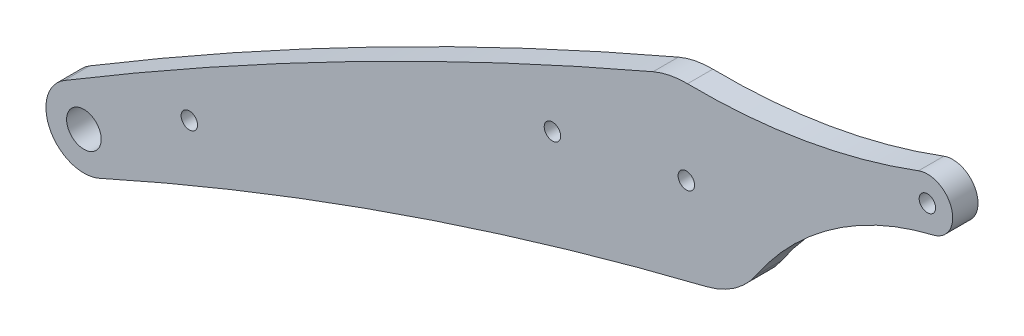
from build123d import *

# Parameters (mm, degrees)
SKETCH1_R           = 1.95
SKETCH1_R_2         = 4.1
BOSS_EXTRUDE1_DEPTH = 6


with BuildPart() as part:
    # Sketch1 → Boss-Extrude1 (new body)
    with BuildSketch(Plane.XY):
        with BuildLine():
            ThreePointArc((-249.547735749, 127.673100022), (-252.877471407, 115.79000474), (-241.215192405, 111.754370772))
            ThreePointArc((-241.215192405, 111.754370772), (-170.350070338, 139.847528819), (-97.252990361, 161.478708942))
            ThreePointArc((-97.252990361, 161.478708942), (-90.570551573, 164.523097822), (-85.437324527, 169.774123618))
            ThreePointArc((-85.437324527, 169.774123618), (-67.229564843, 188.321481613), (-43.509998386, 198.94735421))
            ThreePointArc((-43.509998386, 198.94735421), (-39.165402052, 206.535635416), (-47.008101374, 210.402106199))
            ThreePointArc((-47.008101374, 210.402106199), (-73.946915163, 203.086860773), (-101.774691803, 200.889737355))
            ThreePointArc((-101.774691803, 200.889737355), (-105.950118059, 200.510334794), (-109.954702491, 199.268789688))
            ThreePointArc((-109.954702491, 199.268789688), (-180.973525069, 165.854124566), (-249.547735749, 127.673100022))
        make_face()
        with Locations((-102.0625187, 180.89180857)):
            Circle(SKETCH1_R, mode=Mode.SUBTRACT)
        with Locations((-44.903785826, 204.783222318)):
            Circle(SKETCH1_R, mode=Mode.SUBTRACT)
        with Locations((-244.903785826, 119.963772612)):
            Circle(SKETCH1_R_2, mode=Mode.SUBTRACT)
        with Locations((-219.903785826, 134.304249979)):
            Circle(SKETCH1_R, mode=Mode.SUBTRACT)
        with Locations((-133.8125187, 175.069049716)):
            Circle(SKETCH1_R, mode=Mode.SUBTRACT)
    extrude(amount=BOSS_EXTRUDE1_DEPTH)


solid = part.part
